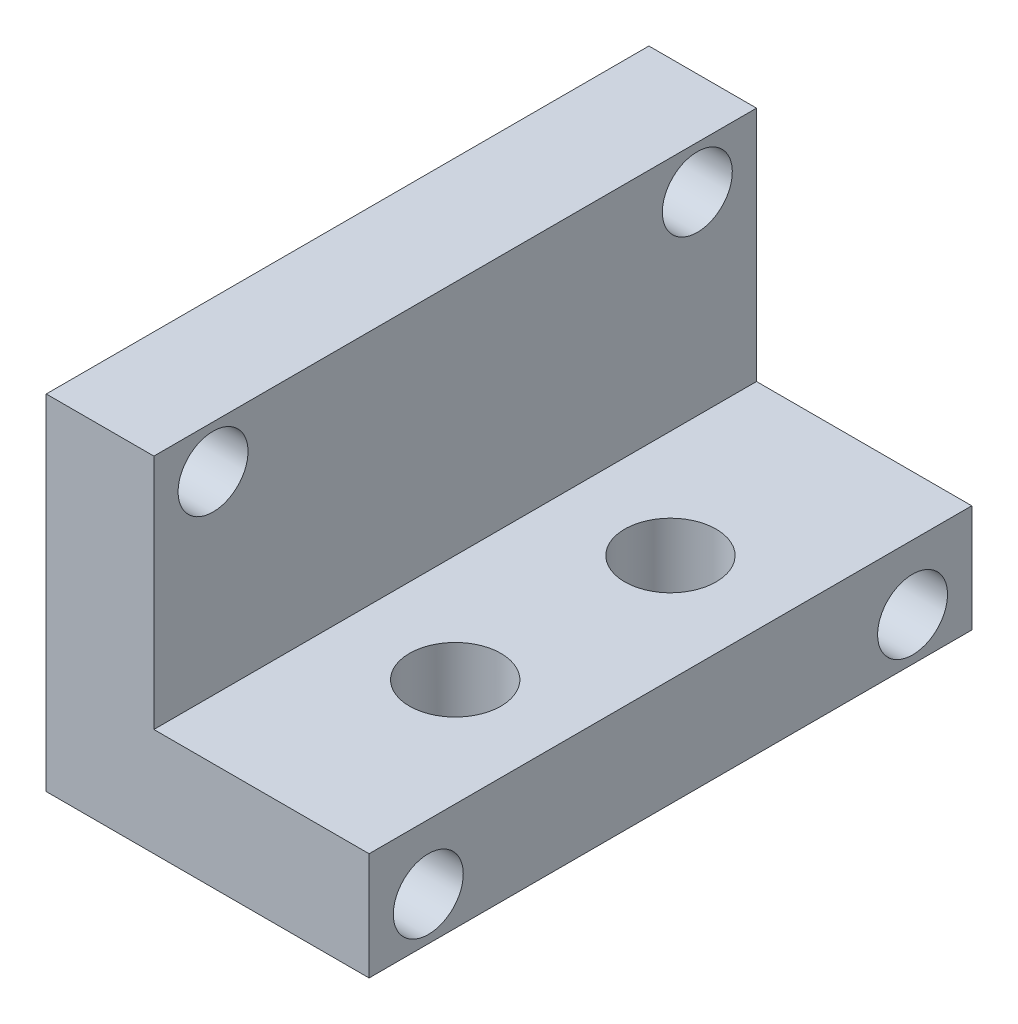
from build123d import *

# Parameters (mm, degrees)
BOSS_EXTRU_1_DEPTH      = 28
ESQUISSE3_R             = 1.625
ENL_V_MAT_EXTRU_1_DEPTH = 16
ESQUISSE4_R             = 2.125
ENL_V_MAT_EXTRU_2_DEPTH = 10


with BuildPart() as part:
    # Esquisse1 → Boss.-Extru.1 (new body)
    with BuildSketch(Plane.XY):
        Polygon((0, 0), (5, 0), (5, -11), (15, -11), (15, -16), (0, -16), align=None)
    extrude(amount=BOSS_EXTRU_1_DEPTH)

    # Esquisse3 → Enlèv. mat.-Extru.1 (cut, through all)
    with BuildSketch(Plane.ZY):
        with Locations((25.25, -2)):
            Circle(ESQUISSE3_R)
        with Locations((2.75, -14)):
            Circle(ESQUISSE3_R)
        with Locations((25.25, -14)):
            Circle(ESQUISSE3_R)
        with Locations((2.75, -2)):
            Circle(ESQUISSE3_R)
    extrude(amount=-ENL_V_MAT_EXTRU_1_DEPTH, mode=Mode.SUBTRACT)

    # Esquisse4 → Enlèv. mat.-Extru.2 (cut)
    with BuildSketch(Plane(origin=(0, -11, 0), x_dir=(1, 0, 0), z_dir=(0, 1, 0))):
        with Locations((10, -9)):
            Circle(ESQUISSE4_R)
        with Locations((10, -19)):
            Circle(ESQUISSE4_R)
    extrude(amount=-ENL_V_MAT_EXTRU_2_DEPTH, mode=Mode.SUBTRACT)


solid = part.part
